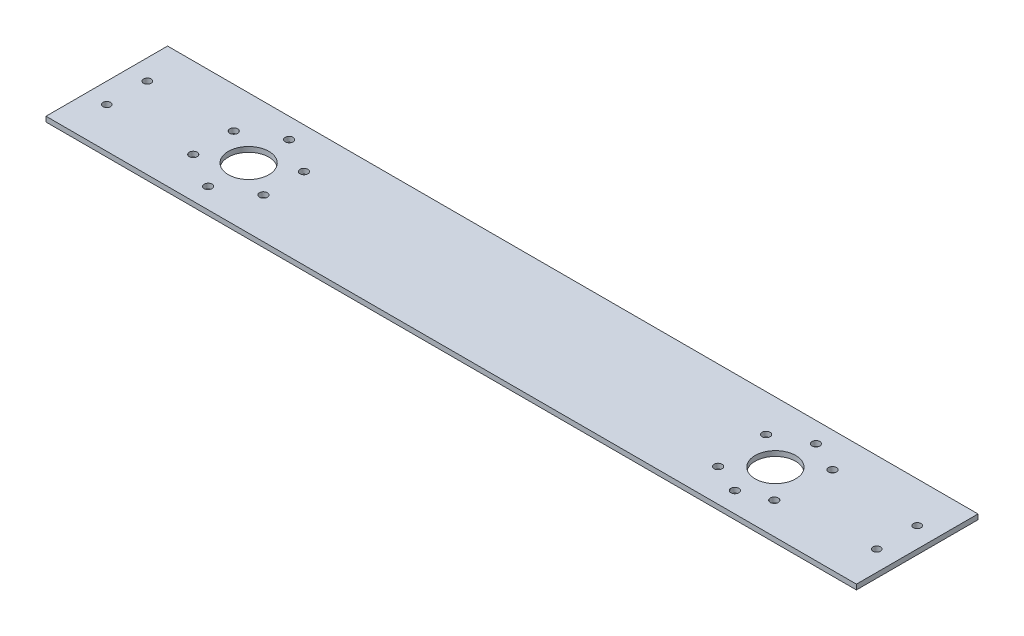
from build123d import *

# Parameters (mm, degrees)
SKETCH1_W               = 508
SKETCH1_H               = 76.2
BOSS_EXTRUDE1_DEPTH     = 3.175
SKETCH3_R               = 2.38125
CUT_EXTRUDE2_DEPTH      = 3.175
SKETCH4_R               = 12.7
CUT_EXTRUDE3_DEPTH      = 1
CUT_EXTRUDE3_DEPTH_BACK = 4.175
SKETCH5_R               = 2.4892
CUT_EXTRUDE4_DEPTH      = 1
CUT_EXTRUDE4_DEPTH_BACK = 4.175


with BuildPart() as part:
    # Sketch1 → Boss-Extrude1 (new body)
    with BuildSketch(Plane(origin=(0, 0, 0), x_dir=(1, 0, 0), z_dir=(0, 1, 0))):
        Rectangle(SKETCH1_W, SKETCH1_H)
    extrude(amount=BOSS_EXTRUDE1_DEPTH)

    # Sketch3 → Cut-Extrude2 (cut)
    with BuildSketch(Plane(origin=(0, 3.175, 0), x_dir=(1, 0, 0), z_dir=(0, 1, 0))):
        with Locations((-241.3, 12.7)):
            Circle(SKETCH3_R)
        with Locations((-241.3, -12.7)):
            Circle(SKETCH3_R)
        with Locations((241.3, -12.7)):
            Circle(SKETCH3_R)
        with Locations((241.3, 12.7)):
            Circle(SKETCH3_R)
    extrude(amount=-CUT_EXTRUDE2_DEPTH, mode=Mode.SUBTRACT)

    # Sketch4 → Cut-Extrude3 (cut, two sides)
    with BuildSketch(Plane(origin=(0, 3.175, 0), x_dir=(1, 0, 0), z_dir=(0, 1, 0))) as cut_extrude3_sk:
        with Locations((-165.1, 0)):
            Circle(SKETCH4_R)
        with Locations((165.1, 0)):
            Circle(SKETCH4_R)
    extrude(amount=CUT_EXTRUDE3_DEPTH, mode=Mode.SUBTRACT)
    extrude(cut_extrude3_sk.sketch, amount=-CUT_EXTRUDE3_DEPTH_BACK, mode=Mode.SUBTRACT)

    # Sketch5 → Cut-Extrude4 (cut, two sides)
    with BuildSketch(Plane(origin=(0, 3.175, 0), x_dir=(1, 0, 0), z_dir=(0, 1, 0))) as cut_extrude4_sk:
        with Locations((165.1, 25.4)):
            Circle(SKETCH5_R)
        with Locations((165.1, -25.4)):
            Circle(SKETCH5_R)
        with Locations((182.702284282, -18.311733617)):
            Circle(SKETCH5_R)
        with Locations((146.781232197, -17.594963659)):
            Circle(SKETCH5_R)
        with Locations((144.478364545, 14.829300427)):
            Circle(SKETCH5_R)
        with Locations((184.428439169, 16.479424725)):
            Circle(SKETCH5_R)
        with Locations((-165.1, 25.4)):
            Circle(SKETCH5_R)
        with Locations((-165.1, -25.4)):
            Circle(SKETCH5_R)
        with Locations((-143.102954744, -12.7)):
            Circle(SKETCH5_R)
        with Locations((-143.102954744, 12.7)):
            Circle(SKETCH5_R)
        with Locations((-187.097045256, 12.7)):
            Circle(SKETCH5_R)
        with Locations((-187.097045256, -12.7)):
            Circle(SKETCH5_R)
    extrude(amount=CUT_EXTRUDE4_DEPTH, mode=Mode.SUBTRACT)
    extrude(cut_extrude4_sk.sketch, amount=-CUT_EXTRUDE4_DEPTH_BACK, mode=Mode.SUBTRACT)


solid = part.part
